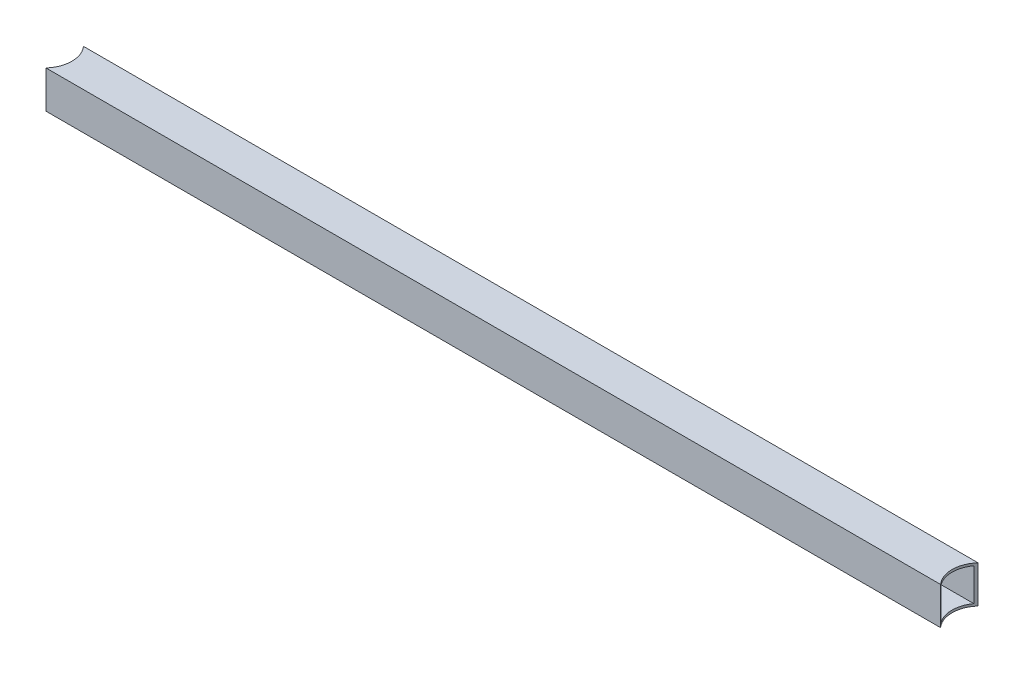
from build123d import *

# Parameters (mm, degrees)
SKETCH1_W           = 25.4
SKETCH1_H           = 25.4
SKETCH1_W_2         = 22.225
SKETCH1_H_2         = 22.225
BOSS_EXTRUDE1_DEPTH = 635
SKETCH2_R           = 19.05
CUT_EXTRUDE1_DEPTH  = 26.4


with BuildPart() as part:
    # Sketch1 → Boss-Extrude1 (new body)
    with BuildSketch(Plane(origin=(0, 0, 0), x_dir=(0, 0, -1), z_dir=(1, 0, 0))):
        with Locations((12.7, 12.7)):
            Rectangle(SKETCH1_W, SKETCH1_H)
        with Locations((12.7, 12.7)):
            Rectangle(SKETCH1_W_2, SKETCH1_H_2, mode=Mode.SUBTRACT)
    extrude(amount=BOSS_EXTRUDE1_DEPTH)

    # Sketch2 → Cut-Extrude1 (cut, through all)
    with BuildSketch(Plane(origin=(0, 25.4, 0), x_dir=(1, 0, 0), z_dir=(0, 1, 0))):
        with Locations((0, 12.7)):
            Circle(SKETCH2_R)
        with Locations((635, 12.7)):
            Circle(SKETCH2_R)
    extrude(amount=-CUT_EXTRUDE1_DEPTH, mode=Mode.SUBTRACT)


solid = part.part
